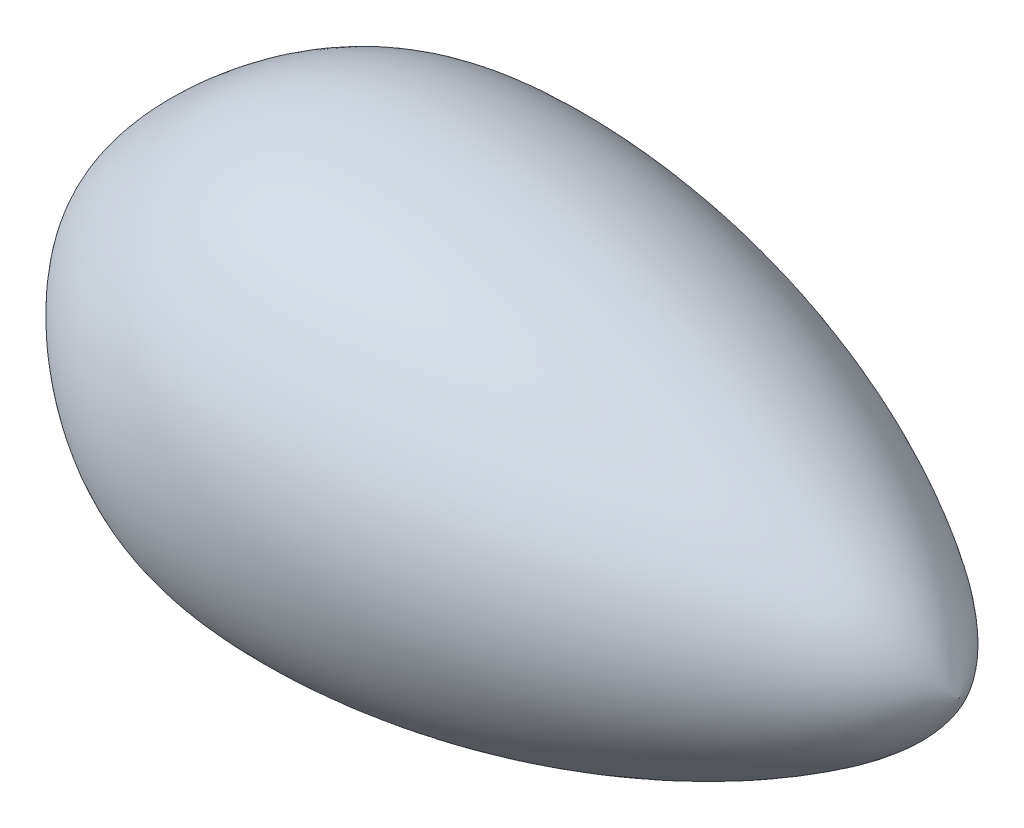
from build123d import *


with BuildPart() as part:
    # Esquisse1 → Révolution1 (revolve)
    with BuildSketch(Plane(origin=(0, 0, 0), x_dir=(1, 0, 0), z_dir=(0, 1, 0))):
        with BuildLine():
            Line((0, 0), (2370, 0))
            add(Edge.make_bspline(
                [(0, 0), (4.704187229, 30.000593164), (3.127794612, 179.122704388), (368.51829936, 571.440863917), (1076.416842801, 685.903289483), (1909.857851842, 454.428714377), (2319.870904682, 127.330816596), (2370, 0)],
                knots=[0, 0, 0, 0, 0.042416947, 0.222213563, 0.402800654, 0.85593857, 1, 1, 1, 1], degree=3))
        make_face()
    revolve(axis=Axis((-269.615809876, 0, 0), (1, 0, 0)))


solid = part.part
